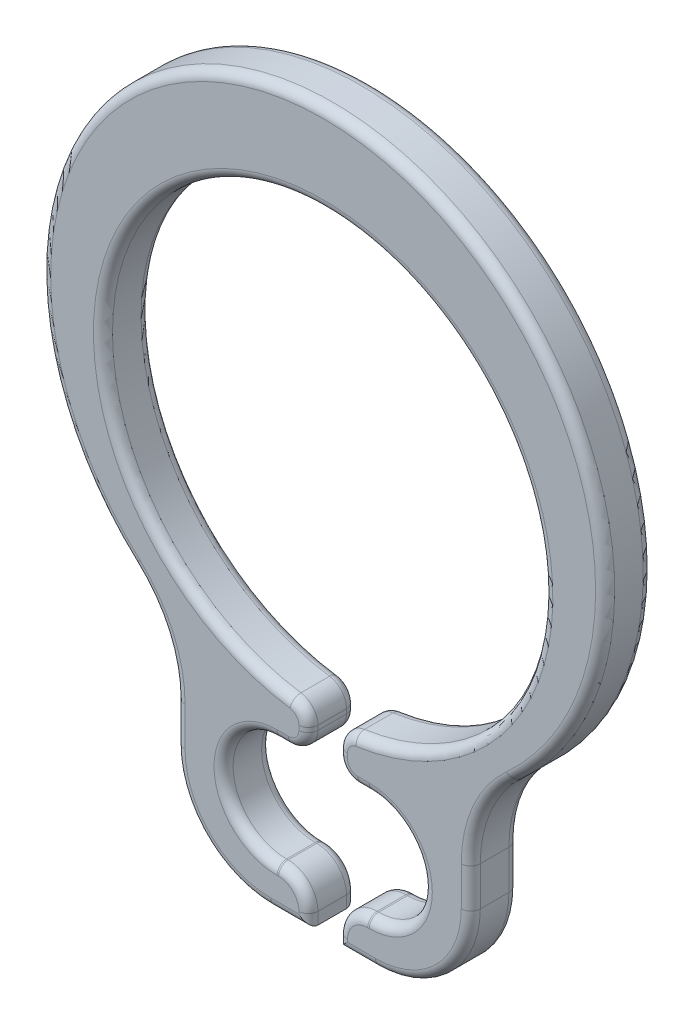
from build123d import *

# Parameters (mm, degrees)
SKETCH3_R                    = 3.7
BOSS_EXTRUDE1_DEPTH          = 0.4
SKETCH4_W                    = 0.496
SKETCH4_H                    = 6.9
CUT_EXTRUDE_THIN1_DEPTH      = 1.4
CUT_EXTRUDE_THIN1_DEPTH_BACK = 1.4
FILLET2_R                    = 0.5
FILLET3_R                    = 0.333333333
FILLET1_R                    = 0.16


with BuildPart() as part:
    # Sketch3 → Boss-Extrude1 (new body, symmetric)
    with BuildSketch(Plane.XY):
        with BuildLine():
            Line((2.48, -3.792248558), (2.48, -4.45))
            ThreePointArc((2.48, -4.45), (2.01137085, -5.58137085), (0.88, -6.05))
            Line((0.88, -6.05), (-0.88, -6.05))
            ThreePointArc((-0.88, -6.05), (-2.01137085, -5.58137085), (-2.48, -4.45))
            Line((-2.48, -4.45), (-2.48, -3.792248558))
            ThreePointArc((-2.48, -3.792248558), (-2.664788291, -2.917510816), (-3.187576477, -2.192248558))
            ThreePointArc((-3.187576477, -2.192248558), (0, 6.05), (3.187576477, -2.192248558))
            ThreePointArc((3.187576477, -2.192248558), (2.664788291, -2.917510816), (2.48, -3.792248558))
        make_face()
        with Locations((0, 0.85)):
            Circle(SKETCH3_R, mode=Mode.SUBTRACT)
        with BuildLine():
            Line((-0.774, -3.55), (0.774, -3.55))
            ThreePointArc((0.774, -3.55), (1.674, -4.45), (0.774, -5.35))
            Line((0.774, -5.35), (-0.774, -5.35))
            ThreePointArc((-0.774, -5.35), (-1.674, -4.45), (-0.774, -3.55))
        make_face(mode=Mode.SUBTRACT)
    extrude(amount=BOSS_EXTRUDE1_DEPTH, both=True)

    # Sketch4 → Cut-Extrude-Thin1 (cut, two sides)
    with BuildSketch(Plane.XY) as cut_extrude_thin1_sk:
        with Locations((0, -2.6)):
            Rectangle(SKETCH4_W, SKETCH4_H)
    extrude(amount=CUT_EXTRUDE_THIN1_DEPTH, mode=Mode.SUBTRACT)
    extrude(cut_extrude_thin1_sk.sketch, amount=-CUT_EXTRUDE_THIN1_DEPTH_BACK, mode=Mode.SUBTRACT)

    # Fillet2
    fillet2_edges = [part.edges().sort_by_distance(p)[0] for p in [
        (-0.248, -5.35, 0),
        (0.248, -5.35, 0),
    ]]
    fillet(fillet2_edges, radius=FILLET2_R)

    # Fillet3
    fillet3_edges = [part.edges().sort_by_distance(p)[0] for p in [
        (0.248, -3.55, 0),
        (-0.248, -3.55, 0),
        (-0.248, -2.841679293, 0),
        (0.248, -2.841679293, 0),
    ]]
    fillet(fillet3_edges, radius=FILLET3_R)

    # Fillet1
    fillet1_edges = [part.edges().sort_by_distance(p)[0] for p in [
        (-2.01137085, -5.58137085, 0.4),
        (-2.48, -4.121124279, -0.4),
        (-2.664788291, -2.917510816, -0.4),
        (-0.564, -6.05, 0.4),
        (2.01137085, -5.58137085, 0.4),
        (2.48, -4.121124279, 0.4),
        (2.664788291, -2.917510816, 0.4),
        (0, 6.05, 0.4),
        (-1.674, -4.45, -0.4),
        (-0.761, -5.35, -0.4),
        (1.674, -4.45, -0.4),
        (0.677666667, -3.55, -0.4),
        (-1.674, -4.45, 0.4),
        (-0.761, -5.35, 0.4),
        (1.674, -4.45, 0.4),
        (0.677666667, -3.55, 0.4),
        (-2.664788291, -2.917510816, 0.4),
        (0.564, -6.05, -0.4),
        (0.564, -6.05, 0.4),
        (-2.48, -4.121124279, 0.4),
        (0.761, -5.35, -0.4),
        (0, 6.05, -0.4),
        (0.761, -5.35, 0.4),
        (-0.248, -5.95, 0.4),
        (0.248, -5.95, 0.4),
        (-0.394446609, -5.496446609, 0.4),
        (0.394446609, -5.496446609, 0.4),
        (0.248, -5.95, -0.4),
        (-0.248, -5.95, -0.4),
        (2.664788291, -2.917510816, -0.4),
        (-0.394446609, -5.496446609, -0.4),
        (0.394446609, -5.496446609, -0.4),
        (2.48, -4.121124279, -0.4),
        (2.01137085, -5.58137085, -0.4),
        (0.248, -3.178942848, -0.4),
        (0, 4.55, -0.4),
        (-0.248, -3.178942848, -0.4),
        (-0.677666667, -3.55, -0.4),
        (-0.329216492, -2.923163509, -0.4),
        (-0.564, -6.05, -0.4),
        (-0.345631073, -3.452368927, -0.4),
        (0.329216492, -2.923163509, -0.4),
        (0.345631073, -3.452368927, -0.4),
        (0.248, -3.178942848, 0.4),
        (-0.677666667, -3.55, 0.4),
        (-0.248, -3.178942848, 0.4),
        (-2.01137085, -5.58137085, -0.4),
        (0, 4.55, 0.4),
        (-0.329216492, -2.923163509, 0.4),
        (-0.345631073, -3.452368927, 0.4),
        (0.329216492, -2.923163509, 0.4),
        (0.345631073, -3.452368927, 0.4),
    ]]
    fillet(fillet1_edges, radius=FILLET1_R)


solid = part.part
